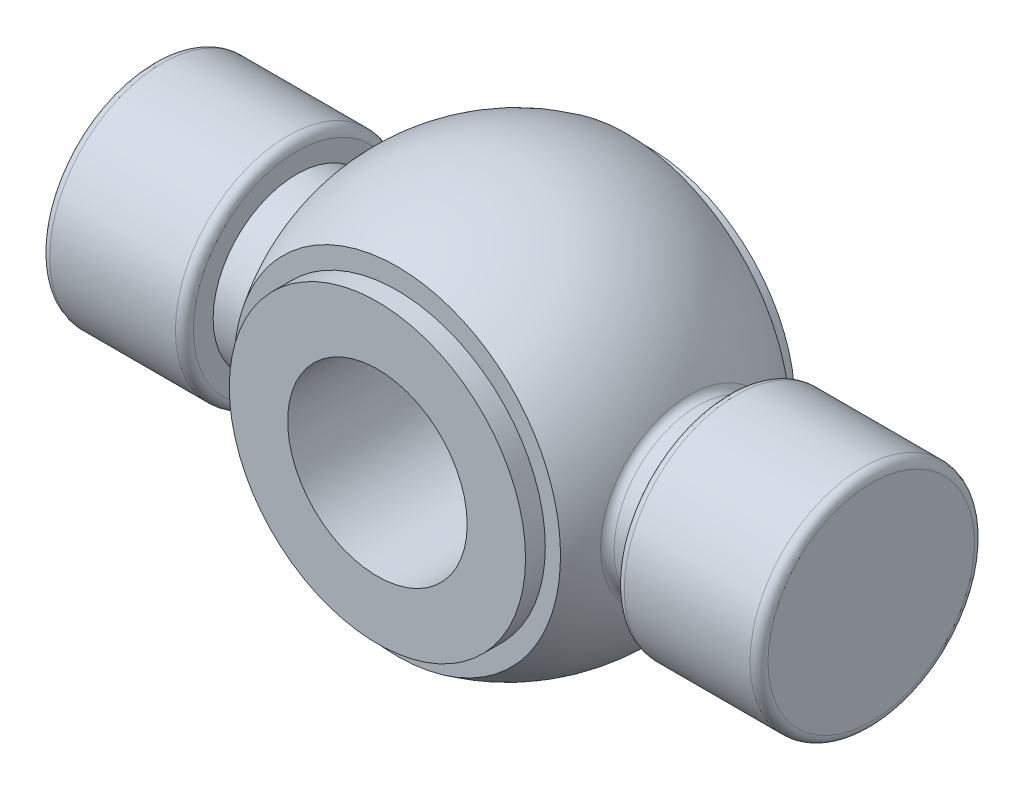
from build123d import *

# Parameters (mm, degrees)
SKETCH2_W               = 25.4
SKETCH2_H               = 15.168817315
SKETCH2_H_2             = 15.538076977
CUT_EXTRUDE1_DEPTH      = 33.592007769
CUT_EXTRUDE1_DEPTH_BACK = 33.592007769
SKETCH3_R               = 10.4775
BOSS_EXTRUDE1_DEPTH     = 9.525
SKETCH4_R               = 6.35
CUT_EXTRUDE2_DEPTH      = 35.879822035
FILLET1_R               = 0.635


with BuildPart() as part:
    # Sketch1 → Revolve1 (revolve)
    with BuildSketch(Plane.XY, mode=Mode.PRIVATE) as revolve1_sk:
        with BuildLine():
            Line((-25.4, 0), (-25.4, 7.9375))
            Line((-25.4, 7.9375), (-15.24, 7.9375))
            Line((-15.24, 7.9375), (-15.24, 5.9055))
            Line((-15.24, 5.9055), (-12.7, 5.9055))
            ThreePointArc((-12.7, 5.9055), (0, 14.440896174), (12.7, 5.9055))
            Line((12.7, 5.9055), (15.24, 5.9055))
            Line((15.24, 5.9055), (15.24, 7.9375))
            Line((15.24, 7.9375), (25.4, 7.9375))
            Line((25.4, 7.9375), (25.4, 0))
            Line((25.4, 0), (-25.4, 0))
        make_face()
    revolve(revolve1_sk.sketch.rotate(Axis((-40.55700935, 0, 0), (1, 0, 0)), 90), axis=Axis((-40.55700935, 0, 0), (1, 0, 0)))

    # Sketch2 → Cut-Extrude1 (cut, two sides)
    with BuildSketch(Plane(origin=(0, 0, 0), x_dir=(1, 0, 0), z_dir=(0, 1, 0))) as cut_extrude1_sk:
        with Locations((0, 15.712408658)):
            Rectangle(SKETCH2_W, SKETCH2_H)
        with Locations((0, -15.897038489)):
            Rectangle(SKETCH2_W, SKETCH2_H_2)
    extrude(amount=CUT_EXTRUDE1_DEPTH, mode=Mode.SUBTRACT)
    extrude(cut_extrude1_sk.sketch, amount=-CUT_EXTRUDE1_DEPTH_BACK, mode=Mode.SUBTRACT)

    # Sketch3 → Boss-Extrude1 (add, symmetric)
    with BuildSketch(Plane.XY):
        with Locations(Location((0, 0, 0), (0, 0, 180))):
            Circle(SKETCH3_R)
    extrude(amount=BOSS_EXTRUDE1_DEPTH, both=True)

    # Sketch4 → Cut-Extrude2 (cut, through all)
    with BuildSketch(Plane.XY.offset(9.525)):
        Circle(SKETCH4_R)
    extrude(amount=-CUT_EXTRUDE2_DEPTH, mode=Mode.SUBTRACT)

    # Fillet1
    fillet1_edges = [part.edges().sort_by_distance(p)[0] for p in [
        (15.24, 0, -7.9375),
        (25.4, 0, -7.9375),
        (-25.4, 0, -7.9375),
        (-15.24, 0, -7.9375),
        (-12.7, 0, -5.9055),
        (12.7, 0, -5.9055),
    ]]
    fillet(fillet1_edges, radius=FILLET1_R)


solid = part.part
